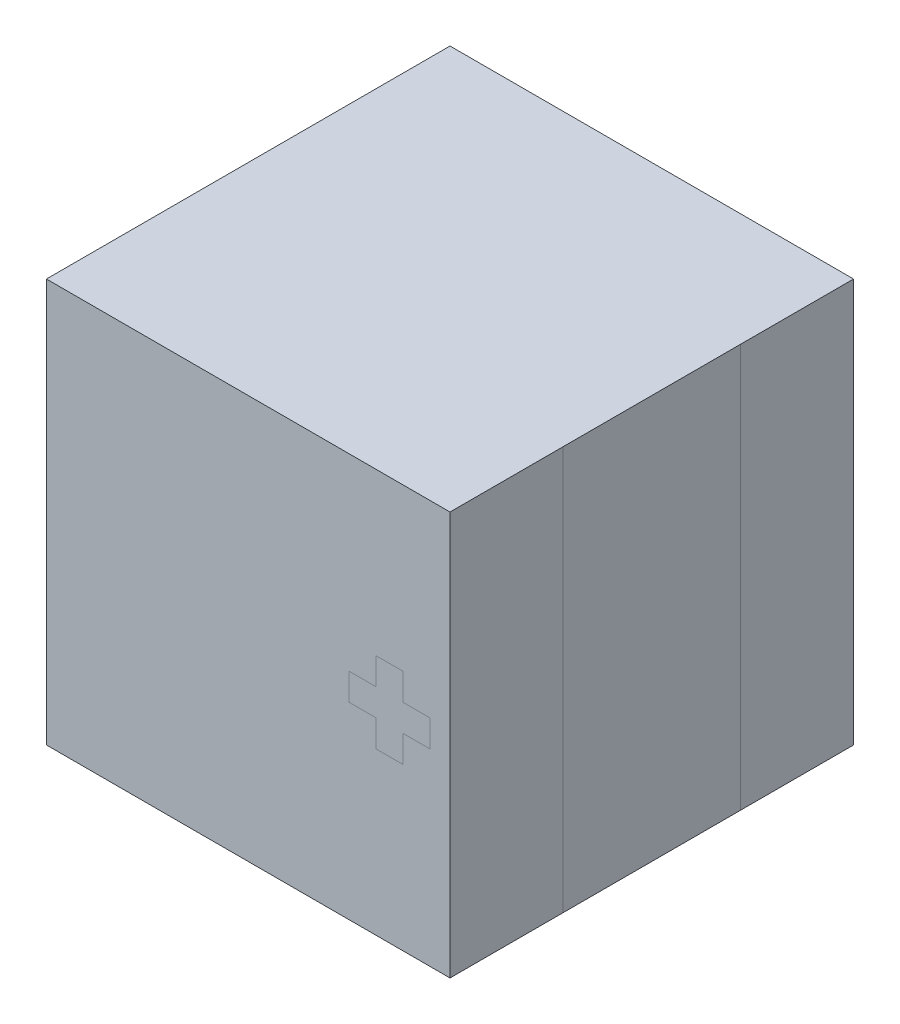
from build123d import *

# Parameters (mm, degrees)
SKETCH1_W           = 5
SKETCH1_H           = 5
BOSS_EXTRUDE1_DEPTH = 5


with BuildPart() as part:
    # Sketch1 → Boss-Extrude1 (new body)
    with BuildSketch(Plane(origin=(0, 0, 0), x_dir=(1, 0, 0), z_dir=(0, 1, 0))):
        Rectangle(SKETCH1_W, SKETCH1_H)
    extrude(amount=BOSS_EXTRUDE1_DEPTH)


solid = part.part
